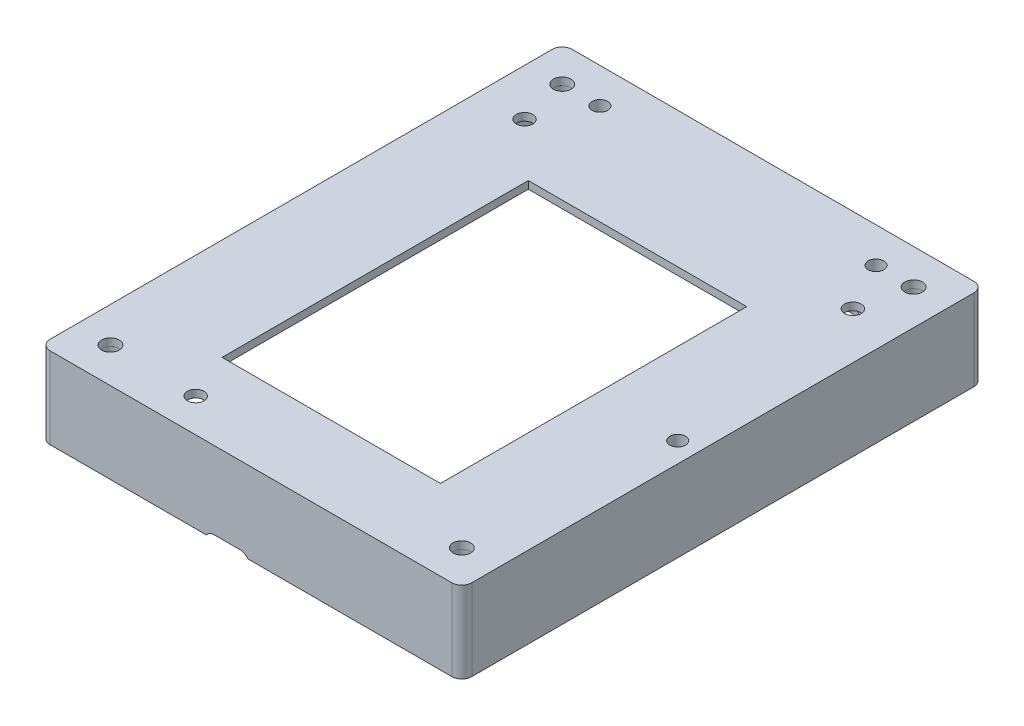
from build123d import *

# Parameters (mm, degrees)
SKETCH_1_W          = 81
SKETCH_1_H          = 101
EXTRUDE_1_DEPTH     = 16.2
SKETCH_2_W          = 81
SKETCH_2_H          = 101
EXTRUDE_2_DEPTH     = 1.5
SKETCH_3_R          = 1.65
SKETCH_3_W          = 43.5
SKETCH_3_H          = 61
CUT_EXTRUDE_1_DEPTH = 1.5
SKETCH_4_R          = 1.75
CUT_EXTRUDE_2_DEPTH = 1.5
CUT_EXTRUDE_3_DEPTH = 1.5
SKETCH_6_R          = 2.25
SKETCH_6_R_2        = 1.75
EXTRUDE_3_DEPTH     = 13.1
EXTRUDE_3_2_DEPTH   = 13.1
EXTRUDE_3_3_DEPTH   = 13.1
EXTRUDE_3_4_DEPTH   = 13.1
SKETCH_7_W          = 13
SKETCH_7_H          = 6
CUT_EXTRUDE_4_DEPTH = 1.5
SKETCH_8_R          = 1.55
CUT_EXTRUDE_5_DEPTH = 17.2
SKETCH_9_R          = 2.358753079
SKETCH_9_R_2        = 1.55
SKETCH_9_R_3        = 2.523223787
SKETCH_9_R_4        = 2.525
EXTRUDE_4_DEPTH     = 5
SKETCH_10_R         = 2.523223787
SKETCH_10_R_2       = 2.358753079
EXTRUDE_5_DEPTH     = 1.5


with BuildPart() as part:
    # 草图1 → 凸台-拉伸1 (new body)
    with BuildSketch(Plane(origin=(0, 0, 0), x_dir=(1, 0, 0), z_dir=(0, 1, 0))):
        with BuildLine():
            Line((-40, 52), (40, 52))
            ThreePointArc((40, 52), (41.414213562, 51.414213562), (42, 50))
            Line((42, 50), (42, -50))
            ThreePointArc((42, -50), (41.414213562, -51.414213562), (40, -52))
            Line((40, -52), (-40, -52))
            ThreePointArc((-40, -52), (-41.414213562, -51.414213562), (-42, -50))
            Line((-42, -50), (-42, 50))
            ThreePointArc((-42, 50), (-41.414213562, 51.414213562), (-40, 52))
        make_face()
        Rectangle(SKETCH_1_W, SKETCH_1_H, mode=Mode.SUBTRACT)
    extrude(amount=EXTRUDE_1_DEPTH)

    # 草图2 → 凸台-拉伸2 (add)
    with BuildSketch(Plane(origin=(0, 16.2, 0), x_dir=(1, 0, 0), z_dir=(0, 1, 0))):
        Rectangle(SKETCH_2_W, SKETCH_2_H)
    extrude(amount=-EXTRUDE_2_DEPTH)

    # 草图3 → 切除-拉伸1 (cut)
    with BuildSketch(Plane(origin=(0, 16.2, 0), x_dir=(1, 0, 0), z_dir=(0, 1, 0))):
        with Locations((-32.7, 35.2)):
            Circle(SKETCH_3_R)
        with Locations((-17.7, -45.3)):
            Circle(SKETCH_3_R)
        with Locations((32.7, 35.2)):
            Circle(SKETCH_3_R)
        with Locations((0, -5.5)):
            Rectangle(SKETCH_3_W, SKETCH_3_H)
    extrude(amount=-CUT_EXTRUDE_1_DEPTH, mode=Mode.SUBTRACT)

    # 草图4 → 切除-拉伸2 (cut)
    with BuildSketch(Plane(origin=(0, 16.2, 0), x_dir=(1, 0, 0), z_dir=(0, 1, 0))):
        with Locations((35, 45)):
            Circle(SKETCH_4_R)
        with Locations((-35, 45)):
            Circle(SKETCH_4_R)
        with Locations((-35, -45)):
            Circle(SKETCH_4_R)
        with Locations((35, -45)):
            Circle(SKETCH_4_R)
    extrude(amount=-CUT_EXTRUDE_2_DEPTH, mode=Mode.SUBTRACT)

    # 草图5 → 切除-拉伸3 (cut)
    with BuildSketch(Plane.XY.offset(52)):
        with BuildLine():
            Line((-7.31, 0.8), (-2.21, 0.8))
            ThreePointArc((-2.21, 0.8), (-0.21, -1.2), (-2.21, -3.2))
            Line((-2.21, -3.2), (-7.31, -3.2))
            ThreePointArc((-7.31, -3.2), (-9.31, -1.2), (-7.31, 0.8))
        make_face()
    extrude(amount=-CUT_EXTRUDE_3_DEPTH, mode=Mode.SUBTRACT)

    # 草图7 → 切除-拉伸4 (cut)
    with BuildSketch(Plane(origin=(0, 0, -52), x_dir=(-1, 0, 0), z_dir=(0, 0, -1))):
        with Locations((16.5, 4.5)):
            Rectangle(SKETCH_7_W, SKETCH_7_H)
    extrude(amount=-CUT_EXTRUDE_4_DEPTH, mode=Mode.SUBTRACT)

    # 草图8 → 切除-拉伸5 (cut, through all)
    with BuildSketch(Plane(origin=(0, 16.2, 0), x_dir=(1, 0, 0), z_dir=(0, 1, 0))):
        with Locations((-27.5, 45)):
            Circle(SKETCH_8_R)
        with Locations((27.5, 45)):
            Circle(SKETCH_8_R)
        with Locations((38, -5)):
            Circle(SKETCH_8_R)
    extrude(amount=-CUT_EXTRUDE_5_DEPTH, mode=Mode.SUBTRACT)

    # 草图9 → 凸台-拉伸4 (add)
    with BuildSketch(Plane.XZ.offset(-14.7)):
        with Locations((-27.5, -45)):
            Circle(SKETCH_9_R)
        with Locations((-27.5, -45)):
            Circle(SKETCH_9_R_2, mode=Mode.SUBTRACT)
        with Locations((27.5, -45)):
            Circle(SKETCH_9_R_3)
        with Locations((27.5, -45)):
            Circle(SKETCH_9_R_2, mode=Mode.SUBTRACT)
        with Locations((38, 5)):
            Circle(SKETCH_9_R_4)
        with Locations((38, 5)):
            Circle(SKETCH_9_R_2, mode=Mode.SUBTRACT)
    extrude(amount=EXTRUDE_4_DEPTH)

    # 草图10 → 凸台-拉伸5 (add)
    with BuildSketch(Plane.XZ.offset(-9.7)):
        with Locations((27.5, -45)):
            Circle(SKETCH_10_R)
        with Locations((-27.5, -45)):
            Circle(SKETCH_10_R_2)
        with BuildLine():
            Line((40.5, 5.354436172), (40.5, 4.645563828))
            ThreePointArc((40.5, 4.645563828), (35.475, 5), (40.5, 5.354436172))
        make_face()
    extrude(amount=EXTRUDE_5_DEPTH)


with BuildPart() as body_2:
    # 草图6 → 凸台-拉伸3 (new body)
    with BuildSketch(Plane.XZ.offset(-14.7)):
        with Locations((-35, 45)):
            Circle(SKETCH_6_R)
        with Locations((-35, 45)):
            Circle(SKETCH_6_R_2, mode=Mode.SUBTRACT)
    extrude(amount=EXTRUDE_3_DEPTH)


with BuildPart() as body_3:
    # 草图6 → Extrude 3 2 (new body)
    with BuildSketch(Plane.XZ.offset(-14.7)):
        with Locations((35, 45)):
            Circle(SKETCH_6_R)
        with Locations((35, 45)):
            Circle(SKETCH_6_R_2, mode=Mode.SUBTRACT)
    extrude(amount=EXTRUDE_3_2_DEPTH)


with BuildPart() as body_4:
    # 草图6 → Extrude 3 3 (new body)
    with BuildSketch(Plane.XZ.offset(-14.7)):
        with Locations((-35, -45)):
            Circle(SKETCH_6_R)
        with Locations((-35, -45)):
            Circle(SKETCH_6_R_2, mode=Mode.SUBTRACT)
    extrude(amount=EXTRUDE_3_3_DEPTH)


with BuildPart() as body_5:
    # 草图6 → Extrude 3 4 (new body)
    with BuildSketch(Plane.XZ.offset(-14.7)):
        with Locations((35, -45)):
            Circle(SKETCH_6_R)
        with Locations((35, -45)):
            Circle(SKETCH_6_R_2, mode=Mode.SUBTRACT)
    extrude(amount=EXTRUDE_3_4_DEPTH)


solid = Compound([part.part, body_2.part, body_3.part, body_4.part, body_5.part])
